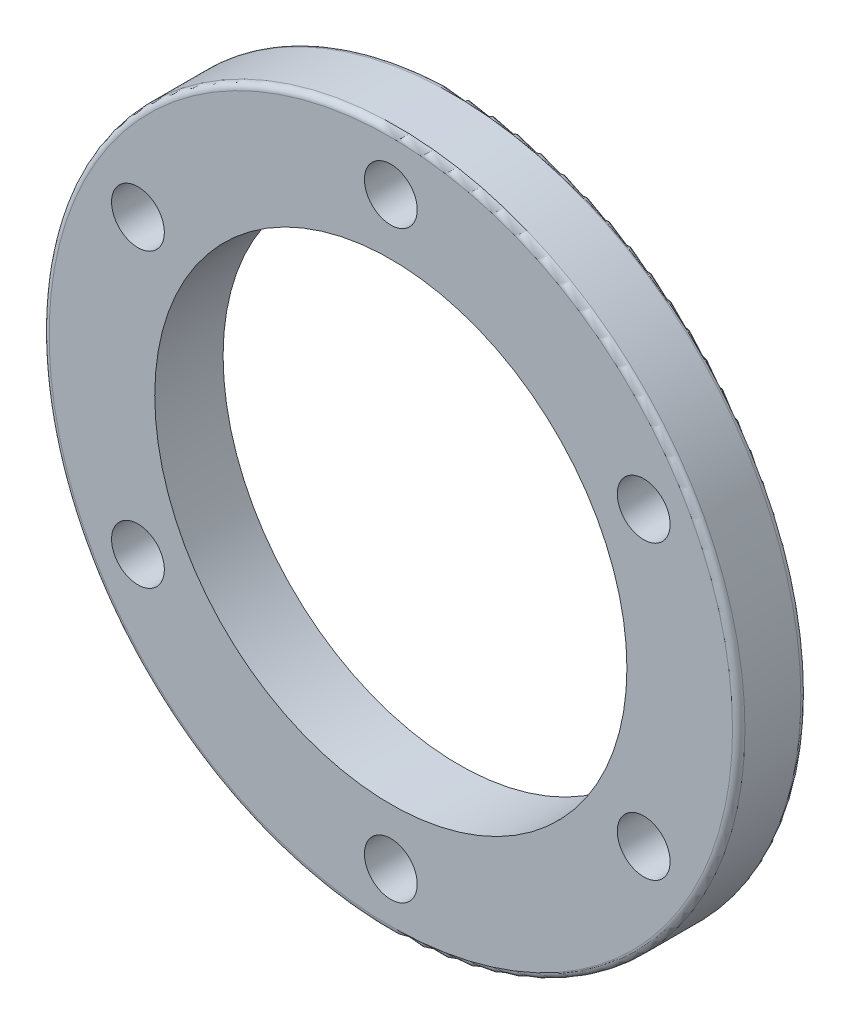
from build123d import *

# Parameters (mm, degrees)
ESQUISSE1_R             = 56
ESQUISSE1_R_2           = 38
BOSS_EXTRU_1_DEPTH      = 11
ESQUISSE2_R             = 4.25
ENL_V_MAT_EXTRU_2_DEPTH = 11
ESQUISSE2_5_R           = 4.25
ENL_V_MAT_EXTRU_3_DEPTH = 12
CONG_1_R                = 1
CONG_2_R                = 1


with BuildPart() as part:
    # Esquisse1 → Boss.-Extru.1 (new body)
    with BuildSketch(Plane.XY):
        Circle(ESQUISSE1_R)
        Circle(ESQUISSE1_R_2, mode=Mode.SUBTRACT)
    extrude(amount=BOSS_EXTRU_1_DEPTH)

    # Esquisse2 → Enl_v. mat.-Extru.2 (cut)
    with BuildSketch(Plane.XY.offset(11)):
        with Locations((0, 47)):
            Circle(ESQUISSE2_R)
    extrude(amount=-ENL_V_MAT_EXTRU_2_DEPTH, mode=Mode.SUBTRACT)

    # Esquisse2_5 → Enl_v. mat.-Extru.3 (cut, through all)
    with BuildSketch(Plane.XY.offset(11)):
        with Locations((0, 47)):
            Circle(ESQUISSE2_5_R)
        with Locations((0, -47)):
            Circle(ESQUISSE2_5_R)
        with Locations((40.703193978, -23.5)):
            Circle(ESQUISSE2_5_R)
        with Locations((40.703193978, 23.5)):
            Circle(ESQUISSE2_5_R)
        with Locations((-40.703193978, 23.5)):
            Circle(ESQUISSE2_5_R)
        with Locations((-40.703193978, -23.5)):
            Circle(ESQUISSE2_5_R)
    extrude(amount=-ENL_V_MAT_EXTRU_3_DEPTH, mode=Mode.SUBTRACT)

    # Cong_1
    cong_1_edges = [part.edges().sort_by_distance(p)[0] for p in [
        (-56, 0, 11),
    ]]
    fillet(cong_1_edges, radius=CONG_1_R)

    # Cong_2
    cong_2_edges = [part.edges().sort_by_distance(p)[0] for p in [
        (-56, 0, 0),
    ]]
    fillet(cong_2_edges, radius=CONG_2_R)


solid = part.part
